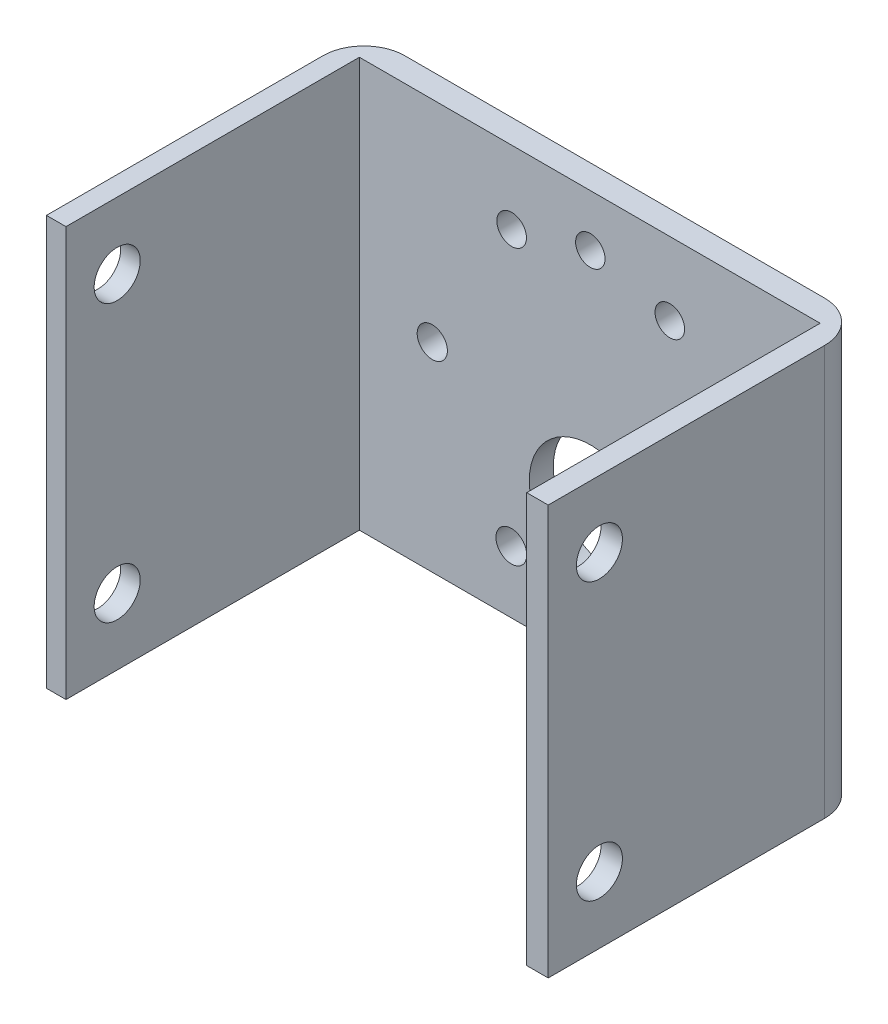
from build123d import *

# Parameters (mm, degrees)
BOSS_EXTRUDE1_DEPTH = 40
FILLET1_R           = 4
SKETCH2_R           = 1.5
SKETCH2_R_2         = 6
CUT_EXTRUDE1_DEPTH  = 40
SKETCH3_R           = 2.25
CUT_EXTRUDE2_DEPTH  = 76
SKETCH4_R           = 1.5
SKETCH4_R_2         = 6
BOSS_EXTRUDE2_DEPTH = 2.346753
SKETCH5_R           = 1.5
SKETCH5_R_2         = 6
CUT_EXTRUDE3_DEPTH  = 10
SKETCH7_W           = 0.19
SKETCH7_H           = 28.653247295
CUT_EXTRUDE4_DEPTH  = 463
SKETCH11_R          = 6
BOSS_EXTRUDE3_DEPTH = 2.346753
SKETCH12_R          = 6
CUT_EXTRUDE7_DEPTH  = 10
SKETCH13_R          = 1.5
BOSS_EXTRUDE4_DEPTH = 2.346753
SKETCH14_R          = 1.475604419
SKETCH14_R_2        = 1.463203764
SKETCH14_R_3        = 1.5
SKETCH14_R_4        = 1.434937512
SKETCH14_R_5        = 1.505191791
SKETCH14_R_6        = 1.44518411
CUT_EXTRUDE8_DEPTH  = 10


with BuildPart() as part:
    # Sketch1 → Boss-Extrude1 (new body)
    with BuildSketch(Plane(origin=(0, 0, 0), x_dir=(1, 0, 0), z_dir=(0, 1, 0))):
        Polygon((-22.403304398, -15.5), (-22.403304398, 13.153247295), (22.214170378, 13.153247295), (22.214170378, -15.5), (24.5, -15.5), (24.5, 15.5), (-24.5, 15.5), (-24.5, -15.5), align=None)
    extrude(amount=BOSS_EXTRUDE1_DEPTH)

    # Fillet1
    fillet1_edges = [part.edges().sort_by_distance(p)[0] for p in [
        (-24.5, 20, -15.5),
        (24.5, 20, -15.5),
    ]]
    fillet(fillet1_edges, radius=FILLET1_R)

    # Sketch2 → Cut-Extrude1 (cut)
    with BuildSketch(Plane(origin=(0, 0, -15.5), x_dir=(-1, 0, 0), z_dir=(0, 0, -1))):
        with Locations((14, 20)):
            Circle(SKETCH2_R)
        with Locations((-17, 20)):
            Circle(SKETCH2_R)
        with Locations((-1.5, 4.5)):
            Circle(SKETCH2_R)
        with Locations((-1.5, 35.5)):
            Circle(SKETCH2_R)
        with Locations((-9.25, 6.576606241)):
            Circle(SKETCH2_R)
        with Locations((-9.25, 33.423393759)):
            Circle(SKETCH2_R)
        with Locations((6.25, 33.423393759)):
            Circle(SKETCH2_R)
        with Locations((6.25, 6.576606241)):
            Circle(SKETCH2_R)
        with Locations((-1.5, 13)):
            Circle(SKETCH2_R_2)
    extrude(amount=-CUT_EXTRUDE1_DEPTH, mode=Mode.SUBTRACT)

    # Sketch3 → Cut-Extrude2 (cut)
    with BuildSketch(Plane.ZY.offset(24.5)):
        with Locations((10.5, 6.5)):
            Circle(SKETCH3_R)
        with Locations((10.5, 33.5)):
            Circle(SKETCH3_R)
    extrude(amount=-CUT_EXTRUDE2_DEPTH, mode=Mode.SUBTRACT)

    # Sketch4 → Boss-Extrude2 (add)
    with BuildSketch(Plane(origin=(0, 0, -15.5), x_dir=(-1, 0, 0), z_dir=(0, 0, -1))):
        with Locations((6.25, 33.423393759)):
            Circle(SKETCH4_R)
        with Locations((14, 20)):
            Circle(SKETCH4_R)
        with Locations((6.25, 6.576606241)):
            Circle(SKETCH4_R)
        with Locations((-1.5, 4.5)):
            Circle(SKETCH4_R)
        with Locations((-9.25, 6.576606241)):
            Circle(SKETCH4_R)
        with Locations((-17, 20)):
            Circle(SKETCH4_R)
        with Locations((-1.5, 35.5)):
            Circle(SKETCH4_R)
        with Locations((-9.25, 33.423393759)):
            Circle(SKETCH4_R)
        with Locations((-1.5, 13)):
            Circle(SKETCH4_R_2)
    extrude(amount=-BOSS_EXTRUDE2_DEPTH)

    # Sketch5 → Cut-Extrude3 (cut)
    with BuildSketch(Plane(origin=(0, 0, -15.5), x_dir=(-1, 0, 0), z_dir=(0, 0, -1))):
        with Locations((15.5, 20)):
            Circle(SKETCH5_R)
        with Locations((0, 4.5)):
            Circle(SKETCH5_R)
        with Locations((-15.5, 20)):
            Circle(SKETCH5_R)
        with Locations((0, 35.5)):
            Circle(SKETCH5_R)
        with Locations((7.75, 33.423393759)):
            Circle(SKETCH5_R)
        with Locations((-7.75, 33.423393759)):
            Circle(SKETCH5_R)
        with Locations((-7.75, 6.576606241)):
            Circle(SKETCH5_R)
        with Locations((7.75, 6.576606241)):
            Circle(SKETCH5_R)
        with Locations((0, 13)):
            Circle(SKETCH5_R_2)
    extrude(amount=-CUT_EXTRUDE3_DEPTH, mode=Mode.SUBTRACT)

    # Sketch7 → Cut-Extrude4 (cut)
    with BuildSketch(Plane.XZ):
        with Locations((-22.498304398, 1.173376353)):
            Rectangle(SKETCH7_W, SKETCH7_H)
        with Locations((22.309170378, 1.173376353)):
            Rectangle(SKETCH7_W, SKETCH7_H)
    extrude(amount=-CUT_EXTRUDE4_DEPTH, mode=Mode.SUBTRACT)

    # Sketch11 → Boss-Extrude3 (add)
    with BuildSketch(Plane(origin=(0, 0, -15.5), x_dir=(-1, 0, 0), z_dir=(0, 0, -1))):
        with Locations((0, 13)):
            Circle(SKETCH11_R)
    extrude(amount=-BOSS_EXTRUDE3_DEPTH)

    # Sketch12 → Cut-Extrude7 (cut)
    with BuildSketch(Plane(origin=(0, 0, -15.5), x_dir=(-1, 0, 0), z_dir=(0, 0, -1))):
        with Locations((0, 12.5)):
            Circle(SKETCH12_R)
    extrude(amount=-CUT_EXTRUDE7_DEPTH, mode=Mode.SUBTRACT)

    # Sketch13 → Boss-Extrude4 (add)
    with BuildSketch(Plane(origin=(0, 0, -15.5), x_dir=(-1, 0, 0), z_dir=(0, 0, -1))):
        with Locations((7.75, 6.576606241)):
            Circle(SKETCH13_R)
        with Locations((0, 4.5)):
            Circle(SKETCH13_R)
        with Locations((-7.75, 6.576606241)):
            Circle(SKETCH13_R)
        with Locations((-15.5, 20)):
            Circle(SKETCH13_R)
        with Locations((-7.75, 33.423393759)):
            Circle(SKETCH13_R)
        with Locations((0, 35.5)):
            Circle(SKETCH13_R)
        with Locations((7.75, 33.423393759)):
            Circle(SKETCH13_R)
        with Locations((15.5, 20)):
            Circle(SKETCH13_R)
    extrude(amount=-BOSS_EXTRUDE4_DEPTH)

    # Sketch14 → Cut-Extrude8 (cut)
    with BuildSketch(Plane(origin=(0, 0, -15.5), x_dir=(-1, 0, 0), z_dir=(0, 0, -1))):
        with Locations((15.475197646, 19.465354549)):
            Circle(SKETCH14_R)
        with Locations((-15.475197646, 19.465354549)):
            Circle(SKETCH14_R_2)
        with Locations((0, 3.990156903)):
            Circle(SKETCH14_R_3)
        with Locations((0.042141816, 34.934937512)):
            Circle(SKETCH14_R_4)
        with Locations((7.752595896, 6.072110018)):
            Circle(SKETCH14_R_5)
        with Locations((-7.752600927, 6.072112931)):
            Circle(SKETCH14_R_3)
        with Locations((-7.722592055, 32.875921806)):
            Circle(SKETCH14_R_6)
        with Locations((7.722592055, 32.875921806)):
            Circle(SKETCH14_R_6)
    extrude(amount=-CUT_EXTRUDE8_DEPTH, mode=Mode.SUBTRACT)


solid = part.part
